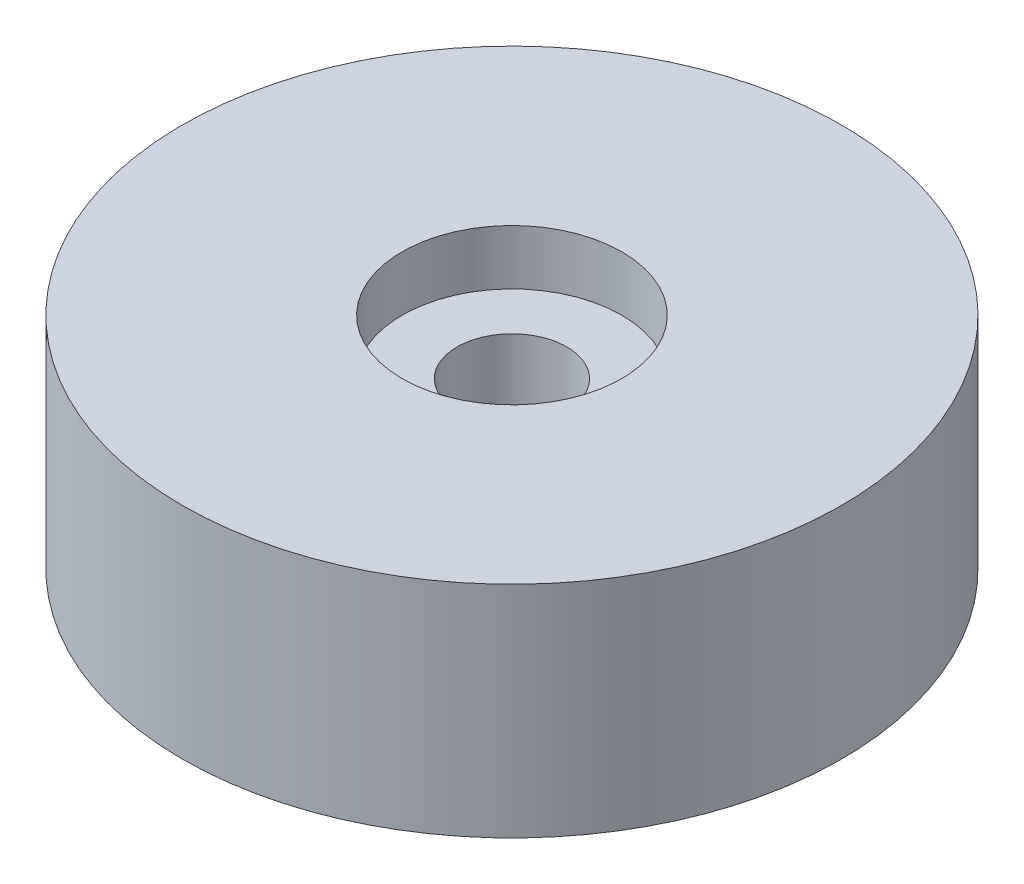
from build123d import *

# Parameters (mm, degrees)
SKETCH1_R           = 19.05
BOSS_EXTRUDE1_DEPTH = 12.7
SKETCH2_R           = 3.175
CUT_EXTRUDE1_DEPTH  = 17.78
SKETCH3_R           = 6.35
CUT_EXTRUDE2_DEPTH  = 3.175


with BuildPart() as part:
    # Sketch1 → Boss-Extrude1 (new body)
    with BuildSketch(Plane(origin=(0, 0, 0), x_dir=(1, 0, 0), z_dir=(0, 1, 0))):
        Circle(SKETCH1_R)
    extrude(amount=-BOSS_EXTRUDE1_DEPTH)

    # Sketch2 → Cut-Extrude1 (cut)
    with BuildSketch(Plane(origin=(0, 0, 0), x_dir=(1, 0, 0), z_dir=(0, 1, 0))):
        Circle(SKETCH2_R)
    extrude(amount=-CUT_EXTRUDE1_DEPTH, mode=Mode.SUBTRACT)

    # Sketch3 → Cut-Extrude2 (cut)
    with BuildSketch(Plane(origin=(0, 0, 0), x_dir=(1, 0, 0), z_dir=(0, 1, 0))):
        Circle(SKETCH3_R)
    extrude(amount=-CUT_EXTRUDE2_DEPTH, mode=Mode.SUBTRACT)


solid = part.part
